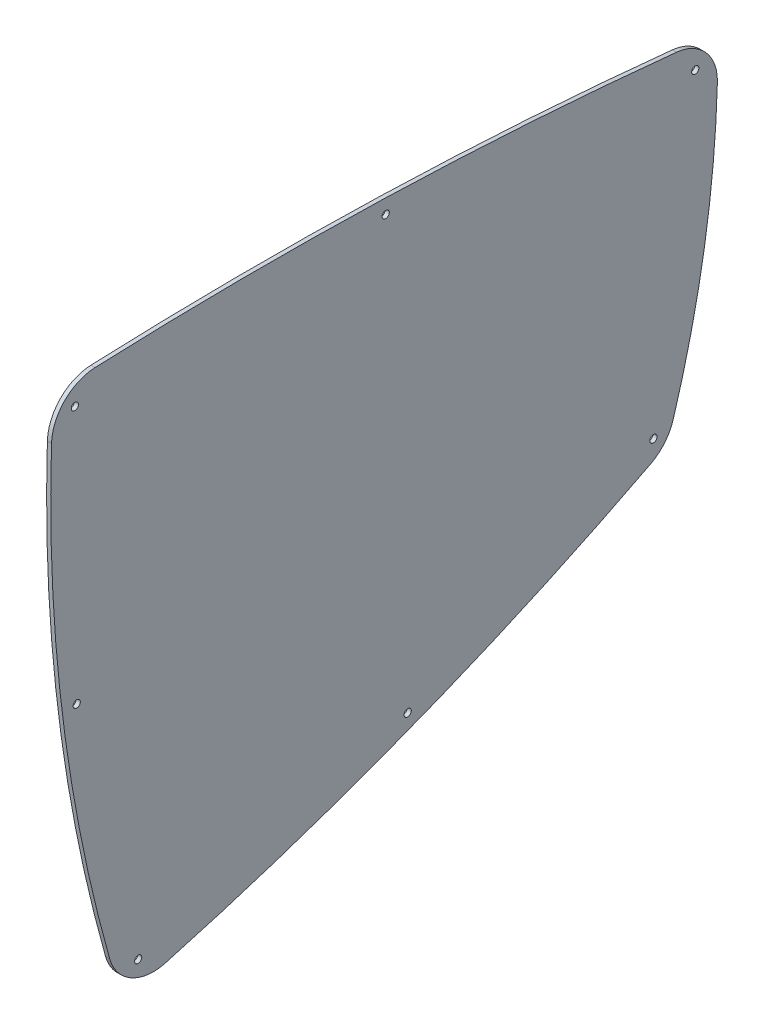
from build123d import *

# Parameters (mm, degrees)
CROQUIS2_R              = 1.75
SALIENTE_EXTRUIR1_DEPTH = 2


with BuildPart() as part:
    # Croquis2 → Saliente-Extruir1 (new body)
    with BuildSketch(Plane(origin=(0, 0, 0), x_dir=(0, 0, -1), z_dir=(1, 0, 0))):
        with BuildLine():
            ThreePointArc((-96.614142786, 197.855252051), (-81.453806027, 262.611499523), (-75.165534077, 328.820751393))
            ThreePointArc((-75.165534077, 328.820751393), (-80.625986242, 343.931649954), (-94.904004852, 351.300094686))
            ThreePointArc((-94.904004852, 351.300094686), (-235.692785429, 360.674969525), (-376.791015079, 359.863425139))
            ThreePointArc((-376.791015079, 359.863425139), (-391.509654572, 353.355396757), (-397.859422485, 338.567792847))
            ThreePointArc((-397.859422485, 338.567792847), (-392.587269832, 222.285598409), (-369.665474686, 108.163139426))
            ThreePointArc((-369.665474686, 108.163139426), (-359.307110382, 94.973091226), (-342.66254386, 92.916033167))
            ThreePointArc((-342.66254386, 92.916033167), (-222.709683854, 132.700513572), (-107.551722613, 184.759494235))
            ThreePointArc((-107.551722613, 184.759494235), (-100.761654757, 190.203841513), (-96.614142786, 197.855252051))
        make_face()
        with Locations((-85.886008555, 339.31297425)):
            Circle(CROQUIS2_R, mode=Mode.SUBTRACT)
        with Locations((-235.905337517, 353.678197297)):
            Circle(CROQUIS2_R, mode=Mode.SUBTRACT)
        with Locations((-386.533430085, 348.4322687)):
            Circle(CROQUIS2_R, mode=Mode.SUBTRACT)
        with Locations((-385.639096494, 223.135826186)):
            Circle(CROQUIS2_R, mode=Mode.SUBTRACT)
        with Locations((-355.865347904, 101.068521567)):
            Circle(CROQUIS2_R, mode=Mode.SUBTRACT)
        with Locations((-225.256716861, 139.220684034)):
            Circle(CROQUIS2_R, mode=Mode.SUBTRACT)
        with Locations((-106.134267637, 194.691048979)):
            Circle(CROQUIS2_R, mode=Mode.SUBTRACT)
    extrude(amount=SALIENTE_EXTRUIR1_DEPTH)


solid = part.part
